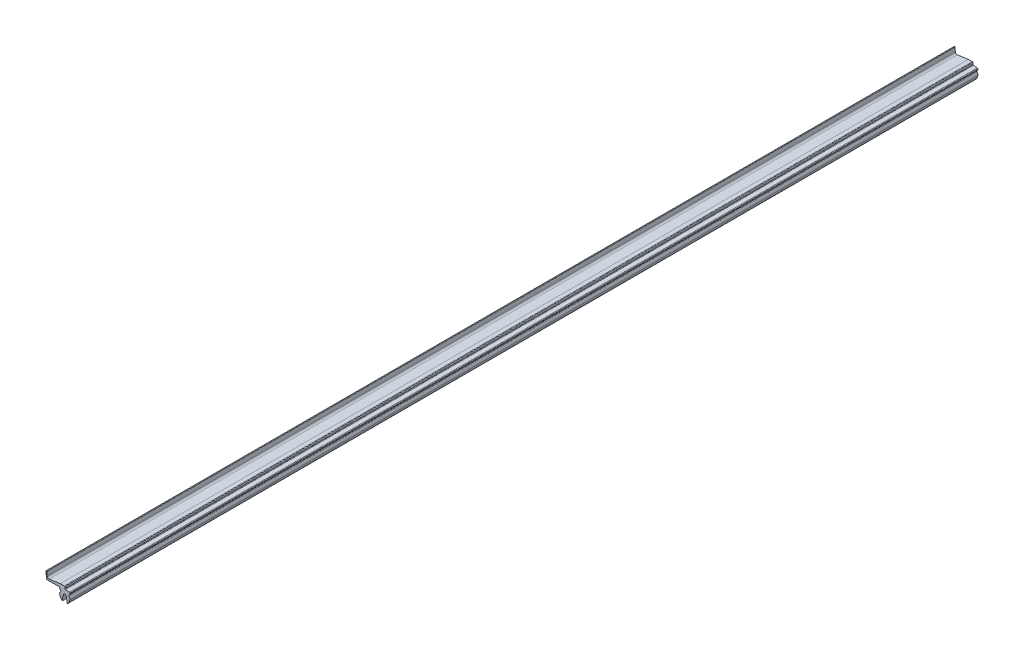
from build123d import *

# Parameters (mm, degrees)
MAIN_EXTRUSION_DEPTH = 1000


with BuildPart() as part:
    # Sk Main Extrusion → Main Extrusion (new body)
    with BuildSketch(Plane.XY):
        with BuildLine():
            Line((-19.564823375, 0), (-5.70955999, 0))
            ThreePointArc((-5.70955999, 0), (-5.414054203, -1.387221791), (-4.643319426, -2.577883736))
            ThreePointArc((-4.643319426, -2.577883736), (-4.376983545, -3.328515195), (-4.743536233, -4.035637189))
            ThreePointArc((-4.743536233, -4.035637189), (-5.549065057, -5.188573329), (-5.624751834, -6.592998458))
            ThreePointArc((-5.624751834, -6.592998458), (-4.784658148, -8.996464386), (-3.4312327, -11.152999901))
            ThreePointArc((-3.4312327, -11.152999901), (-3.019905527, -11.480142613), (-2.506922203, -11.594425189))
            ThreePointArc((-2.506922203, -11.594425189), (-2.291191076, -8.361169229), (-1.583815224, -5.198875216))
            ThreePointArc((-1.583815224, -5.198875216), (0, -4.027016521), (1.583815224, -5.198875216))
            ThreePointArc((1.583815224, -5.198875216), (2.291191076, -8.361169229), (2.506922203, -11.594425189))
            ThreePointArc((2.506922203, -11.594425189), (3.019905527, -11.480142613), (3.4312327, -11.152999901))
            ThreePointArc((3.4312327, -11.152999901), (4.784658148, -8.996464386), (5.624751834, -6.592998458))
            ThreePointArc((5.624751834, -6.592998458), (5.549065057, -5.188573329), (4.743536233, -4.035637189))
            ThreePointArc((4.743536233, -4.035637189), (4.376983545, -3.328515195), (4.643319426, -2.577883736))
            ThreePointArc((4.643319426, -2.577883736), (5.325853836, -1.584808807), (5.673737659, -0.43110699))
            ThreePointArc((5.673737659, -0.43110699), (5.522041744, 0.119270785), (5.017650904, 0.386697835))
            Line((5.017650904, 0.386697835), (0.673438444, 0.736480319))
            ThreePointArc((0.673438444, 0.736480319), (0.231134607, 1.019470764), (0.218560941, 1.544407122))
            ThreePointArc((0.218560941, 1.544407122), (0.362130691, 2.399619674), (0, 3.187567735))
            ThreePointArc((0, 3.187567735), (-0.338135797, 3.434666121), (-0.747703743, 3.522116267))
            Line((-0.747703743, 3.522116267), (-4.928660874, 3.522116267))
            Line((-4.928660874, 3.522116267), (-17.063386647, 1.866924243))
            ThreePointArc((-17.063386647, 1.866924243), (-18.541135771, 2.274001462), (-19.266905518, 3.624080204))
            Line((-19.266905518, 3.624080204), (-19.642313181, 7.836439756))
            ThreePointArc((-19.642313181, 7.836439756), (-20.182201782, 8.290299862), (-20.638789315, 7.752715895))
            Line((-20.638789315, 7.752715895), (-20.063273376, 0.460660486))
            ThreePointArc((-20.063273376, 0.460660486), (-19.904183245, 0.132801309), (-19.564823375, 0))
        make_face()
    extrude(amount=-MAIN_EXTRUSION_DEPTH)


solid = part.part
